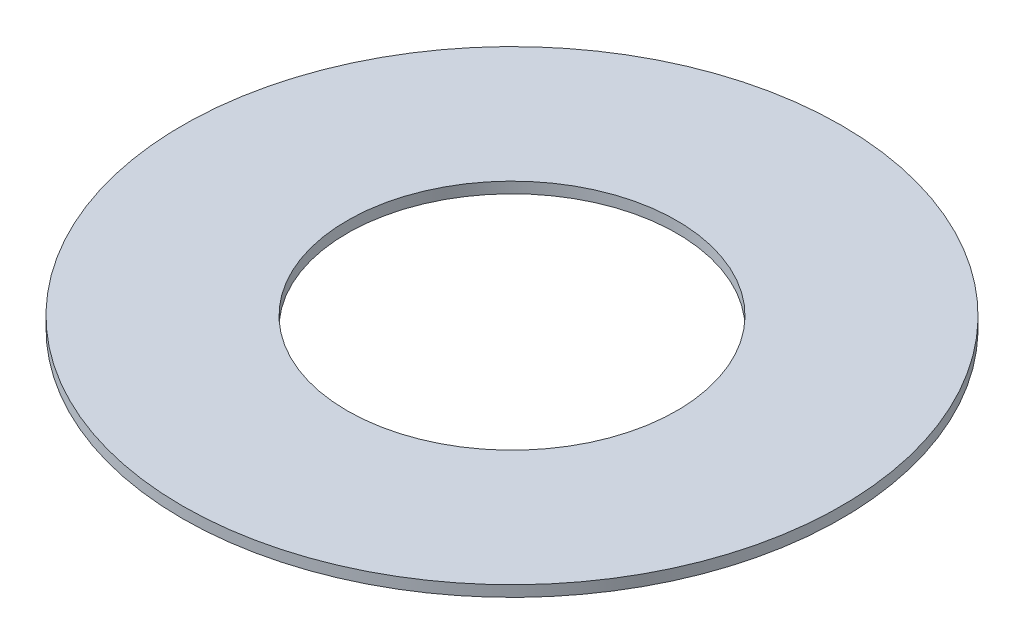
from build123d import *

# Parameters (mm, degrees)
SKETCH1_R           = 6
BOSS_EXTRUDE1_DEPTH = 0.2
SKETCH5_R           = 3
CUT_EXTRUDE1_DEPTH  = 1.2


with BuildPart() as part:
    # Sketch1 → Boss-Extrude1 (new body)
    with BuildSketch(Plane(origin=(0, 0, 0), x_dir=(1, 0, 0), z_dir=(0, 1, 0))):
        Circle(SKETCH1_R)
    extrude(amount=BOSS_EXTRUDE1_DEPTH)

    # Sketch5 → Cut-Extrude1 (cut, through all)
    with BuildSketch(Plane(origin=(0, 0.2, 0), x_dir=(-1, 0, 0), z_dir=(0, 1, 0))):
        Circle(SKETCH5_R)
    extrude(amount=-CUT_EXTRUDE1_DEPTH, mode=Mode.SUBTRACT)


solid = part.part
